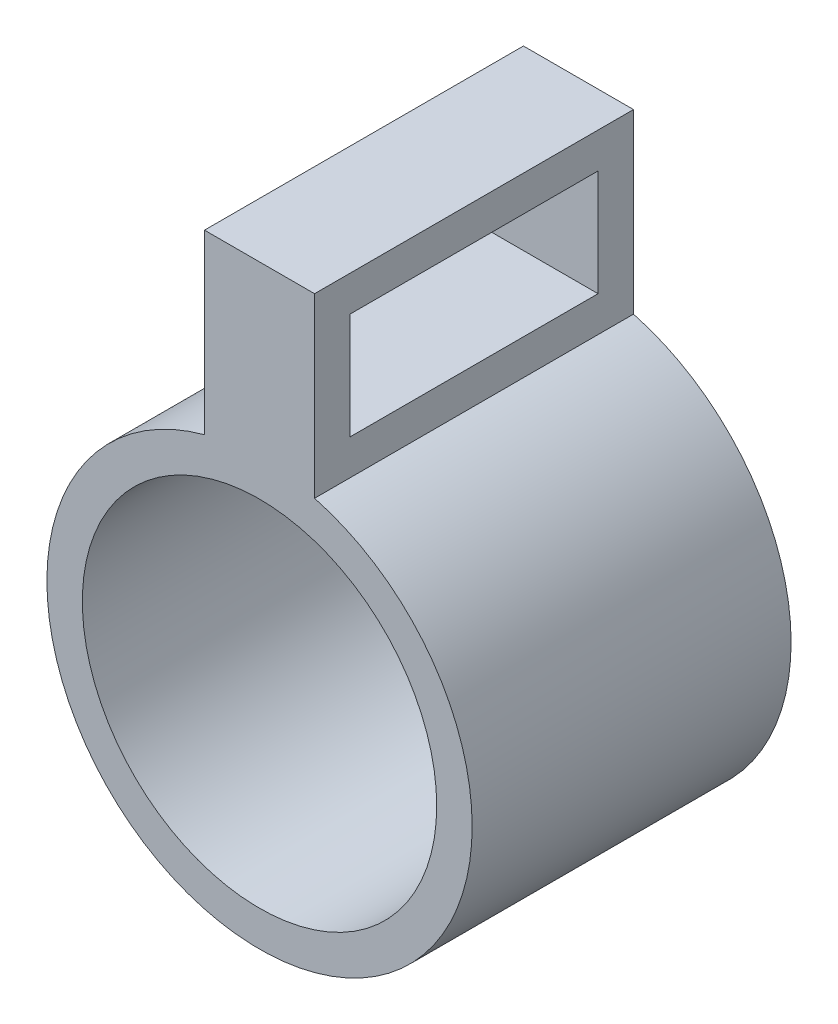
from build123d import *

# Parameters (mm, degrees)
SKETCH1_R           = 10
BOSS_EXTRUDE1_DEPTH = 16
BOSS_EXTRUDE2_DEPTH = 2
SKETCH3_W           = 6
SKETCH3_H           = 14
CUT_EXTRUDE1_DEPTH  = 6.211657


with BuildPart() as part:
    # Sketch1 → Boss-Extrude1 (new body)
    with BuildSketch(Plane(origin=(0, 0, 0), x_dir=(0, 1, 0), z_dir=(0, 0, 1))):
        with BuildLine():
            Line((11.591109915, 3.105828541), (21.591109915, 3.105828541))
            Line((21.591109915, 3.105828541), (21.591109915, -3.105828541))
            Line((21.591109915, -3.105828541), (11.591109915, -3.105828541))
            ThreePointArc((11.591109915, -3.105828541), (-12, 0), (11.591109915, 3.105828541))
        make_face()
        Circle(SKETCH1_R, mode=Mode.SUBTRACT)
    extrude(amount=BOSS_EXTRUDE1_DEPTH)

    # Sketch2 → Boss-Extrude2 (add)
    with BuildSketch(Plane(origin=(0, 0, 0), x_dir=(1, 0, 0), z_dir=(0, 0, -1))):
        with BuildLine():
            Line((-3.105828541, -21.591109915), (3.105828541, -21.591109915))
            Line((3.105828541, -21.591109915), (3.105828541, -11.591109915))
            ThreePointArc((3.105828541, -11.591109915), (0, 12), (-3.105828541, -11.591109915))
            Line((-3.105828541, -11.591109915), (-3.105828541, -21.591109915))
        make_face()
    extrude(amount=BOSS_EXTRUDE2_DEPTH)

    # Sketch3 → Cut-Extrude1 (cut)
    with BuildSketch(Plane.YZ.offset(3.105828541)):
        with Locations((16.591109915, 7)):
            Rectangle(SKETCH3_W, SKETCH3_H)
    extrude(amount=-CUT_EXTRUDE1_DEPTH, mode=Mode.SUBTRACT)


solid = part.part
